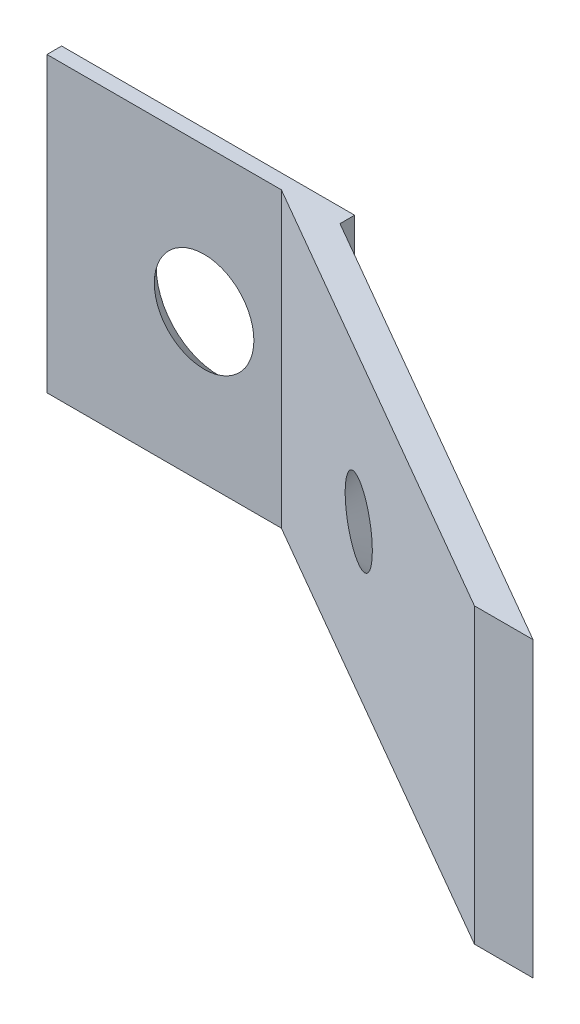
from build123d import *

# Parameters (mm, degrees)
SKETCH2_W                                         = 10
SKETCH2_H                                         = 10
BOSS_EXTRUDE1_DEPTH                               = 0.5
BOSS_EXTRUDE2_DEPTH                               = 10
CSK_FOR_1_FLAT_HEAD_SOCKET_CAP_SCREW1_D           = 2.0574
CSK_FOR_1_FLAT_HEAD_SOCKET_CAP_SCREW1_CSINK_D     = 4.2672
CSK_FOR_1_FLAT_HEAD_SOCKET_CAP_SCREW1_CSINK_ANGLE = 82
CSK_FOR_1_FLAT_HEAD_SOCKET_CAP_SCREW2_D           = 2.0574
CSK_FOR_1_FLAT_HEAD_SOCKET_CAP_SCREW2_CSINK_D     = 4.2672
CSK_FOR_1_FLAT_HEAD_SOCKET_CAP_SCREW2_CSINK_ANGLE = 82


with BuildPart() as part:
    # Sketch2 → Boss-Extrude1 (new body)
    with BuildSketch(Plane.XY):
        with Locations((5, -5)):
            Rectangle(SKETCH2_W, SKETCH2_H)
    extrude(amount=BOSS_EXTRUDE1_DEPTH)

    # Sketch3 → Boss-Extrude2 (add)
    with BuildSketch(Plane.XZ.offset(10)):
        Polygon((8, 0.5), (23.588457268, 9.5), (25.588457268, 9.5), (10, 0.5), align=None)
    extrude(amount=-BOSS_EXTRUDE2_DEPTH)

    # CSK for #1 Flat Head Socket Cap Screw1 (through all)
    with Locations(Plane(origin=(0, 0, 0), x_dir=(-1, 0, 0), z_dir=(0, 0, -1))):
        with Locations((-5.362516401, -4.921292394)):
            CounterSinkHole(CSK_FOR_1_FLAT_HEAD_SOCKET_CAP_SCREW1_D / 2, CSK_FOR_1_FLAT_HEAD_SOCKET_CAP_SCREW1_CSINK_D / 2, counter_sink_angle=CSK_FOR_1_FLAT_HEAD_SOCKET_CAP_SCREW1_CSINK_ANGLE)

    # CSK for #1 Flat Head Socket Cap Screw2 (through all)
    with Locations(Plane(origin=(2.283493649, 0, -3.955127019), x_dir=(-0.866025404, 0, -0.5), z_dir=(0.5, 0, -0.866025404))):
        with Locations((-14.39146791, -4.879407471)):
            CounterSinkHole(CSK_FOR_1_FLAT_HEAD_SOCKET_CAP_SCREW2_D / 2, CSK_FOR_1_FLAT_HEAD_SOCKET_CAP_SCREW2_CSINK_D / 2, counter_sink_angle=CSK_FOR_1_FLAT_HEAD_SOCKET_CAP_SCREW2_CSINK_ANGLE)


solid = part.part
